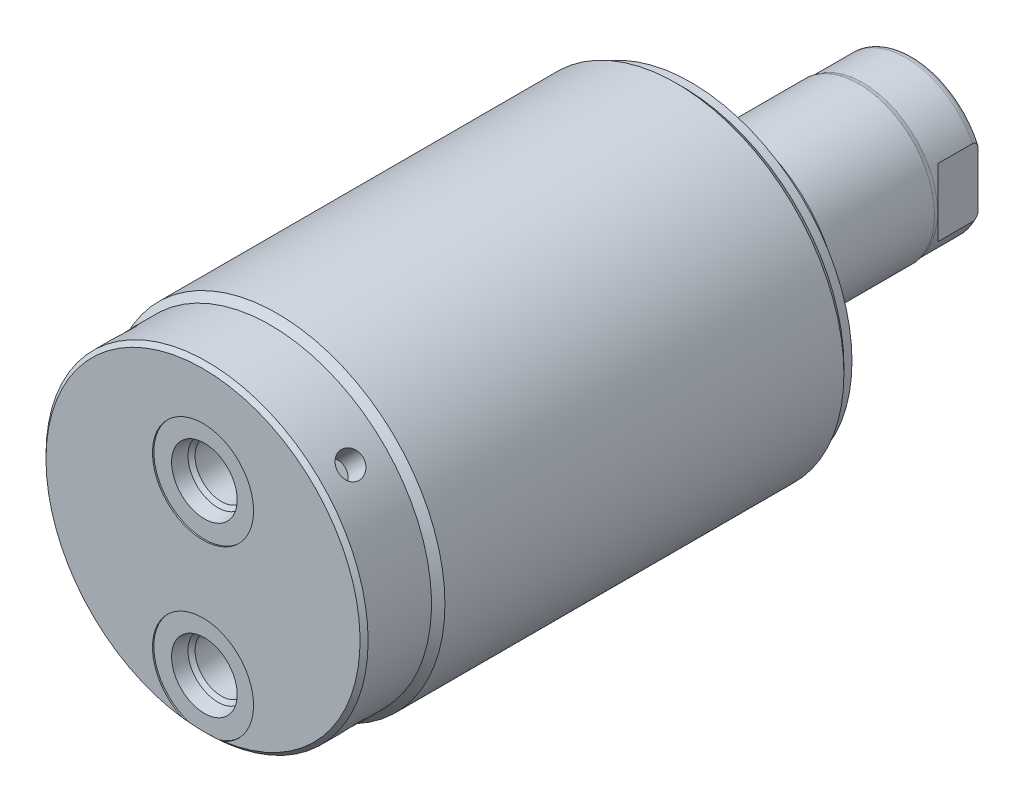
from build123d import *

# Parameters (mm, degrees)
SKETCH1_R          = 31.623
EXTRUDE1_DEPTH     = 91.948
CHAMFER1_SIZE      = 0.762
SKETCH6_R          = 22.225
EXTRUDE2_DEPTH     = 5.969
SKETCH7_W          = 35.56
SKETCH7_H          = 14.2875
CUT_EXTRUDE4_DEPTH = 19.84248
HOLE1_D            = 4.7498
HOLE1_DEPTH        = 4.7498
CIRPATTERN1_COUNT  = 4
LPATTERN2_COUNT    = 2
LPATTERN2_PITCH    = 31.75


with BuildPart() as part:
    # Sketch1 → Extrude1 (new body)
    with BuildSketch(Plane.XY):
        Circle(SKETCH1_R)
    extrude(amount=EXTRUDE1_DEPTH)

    # Sketch2 → Cut-Revolve1 (revolve, cut)
    with BuildSketch(Plane(origin=(0, 0, 0), x_dir=(1, 0, 0), z_dir=(0, 1, 0)), mode=Mode.PRIVATE) as cut_revolve1_sk:
        Polygon((31.623, -91.948), (31.623, -77.978), (30.353, -79.248), (30.353, -91.948), align=None)
    revolve(cut_revolve1_sk.sketch.rotate(Axis((0, 0, 0), (0, 0, 1)), 180), axis=Axis((0, 0, 0), (0, 0, 1)), mode=Mode.SUBTRACT)  # turned: the seam where the file's is

    # Sketch3 → Cut-Revolve2 (revolve, cut)
    with BuildSketch(Plane(origin=(0, 0, 0), x_dir=(1, 0, 0), z_dir=(0, 1, 0)), mode=Mode.PRIVATE) as cut_revolve2_sk:
        Polygon((30.353, 0), (30.353, -1.524), (31.623, -2.794), (31.623, 0), align=None)
    revolve(cut_revolve2_sk.sketch.rotate(Axis((0, 0, 0), (0, 0, -1)), 180), axis=Axis((0, 0, 0), (0, 0, -1)), mode=Mode.SUBTRACT)  # turned: the seam where the file's is

    # S2D0002 → Cut-Revolve3 (revolve, cut)
    with BuildSketch(Plane(origin=(0, 0, 0), x_dir=(0, -1, 0), z_dir=(1, 0, 0)), mode=Mode.PRIVATE) as cut_revolve3_sk:
        Polygon((-4.9403, -91.694), (-1.6002, -91.694), (-1.6002, -91.948), (-11.1252, -91.948), (-11.1252, -77.724), (-6.1468, -77.724), (-6.1468, -88.477393135), (-5.482893135, -89.1413), align=None)
    cut_revolve3 = revolve(cut_revolve3_sk.sketch.rotate(Axis((0, 11.1252, 14.6685), (0, 0, -1)), 270), axis=Axis((0, 11.1252, 14.6685), (0, 0, -1)), mode=Mode.SUBTRACT)  # turned: the seam where the file's is

    # Chamfer1
    chamfer1_edges = [part.edges().sort_by_distance(p)[0] for p in [
        (30.353, 0, 91.948),
    ]]
    chamfer(chamfer1_edges, length=CHAMFER1_SIZE)

    # Sketch6 → Extrude2 (add)
    with BuildSketch(Plane(origin=(0, 0, 0), x_dir=(-1, 0, 0), z_dir=(0, 0, -1))):
        with Locations(Location((0, 0, 0), (0, 0, 180))):  # turned: the seam where the file's is
            Circle(SKETCH6_R)
    extrude(amount=EXTRUDE2_DEPTH)

    # Sketch7 → Revolve1 (revolve)
    with BuildSketch(Plane(origin=(0, 0, 0), x_dir=(0, 0, -1), z_dir=(1, 0, 0)), mode=Mode.PRIVATE) as revolve1_sk:
        with Locations((23.749, -7.14375)):
            Rectangle(SKETCH7_W, SKETCH7_H)
    revolve(revolve1_sk.sketch.rotate(Axis((0, 0, 0), (0, 0, -1)), 270), axis=Axis((0, 0, 0), (0, 0, -1)))  # turned: the seam where the file's is

    # S2D0001 → Cut-Revolve5 (revolve, cut)
    with BuildSketch(Plane(origin=(0, 0, 0), x_dir=(1, 0, 0), z_dir=(0, 1, 0))):
        Polygon((5.5499, 39.461277746), (5.5499, 25.146), (0, 25.146), (0, 41.529), (6.7437, 41.529), align=None)
    revolve(axis=Axis((0, 0, 31.308359971), (0, 0, -1)), mode=Mode.SUBTRACT)

    # Sketch9 → Cut-Revolve6 (revolve, cut)
    with BuildSketch(Plane(origin=(0, 0, 0), x_dir=(0, -1, 0), z_dir=(1, 0, 0)), mode=Mode.PRIVATE) as cut_revolve6_sk:
        with BuildLine():
            Line((-14.2875, 31.623), (-14.097, 32.385))
            Line((-14.097, 32.385), (-14.097, 40.513))
            ThreePointArc((-14.097, 40.513), (-13.996678675, 41.056796865), (-13.708922533, 41.529))
            Line((-13.708922533, 41.529), (-14.2875, 41.529))
            Line((-14.2875, 41.529), (-14.2875, 31.623))
        make_face()
    revolve(cut_revolve6_sk.sketch.rotate(Axis((0, 0, -12.65936), (0, 0, -1)), 90), axis=Axis((0, 0, -12.65936), (0, 0, -1)), mode=Mode.SUBTRACT)  # turned: the seam where the file's is

    # Sketch13 → Cut-Extrude4 (cut, symmetric)
    with BuildSketch(Plane(origin=(0, 0, 0), x_dir=(1, 0, 0), z_dir=(0, 1, 0))):
        Polygon((12.573, 41.529), (12.573, 33.9598), (14.2875, 32.2453), (14.2875, 41.529), align=None)
        Polygon((-12.573, 41.529), (-12.573, 33.9598), (-14.2875, 32.2453), (-14.2875, 41.529), align=None)
    extrude(amount=CUT_EXTRUDE4_DEPTH, both=True, mode=Mode.SUBTRACT)

    # Hole1
    with Locations(Plane(origin=(-21.462812129, 21.462812129, 85.598), x_dir=(0.707106781, 0.707106781, 0), z_dir=(-0.707106781, 0.707106781, 0))):
        with Locations((0, 0)):
            hole1 = Hole(HOLE1_D / 2, depth=HOLE1_DEPTH)

    # CirPattern1: Hole1 ×4 about axis
    cirpattern1_axis = Axis((0, 0, 0), (0, 0, 1))
    for i in range(1, CIRPATTERN1_COUNT):
        add(hole1.rotate(cirpattern1_axis, i * 360 / CIRPATTERN1_COUNT), mode=Mode.SUBTRACT)

    # LPattern2: Cut-Revolve3 ×2
    with Locations(*[(0, -i * LPATTERN2_PITCH, 0) for i in range(1, LPATTERN2_COUNT)]):
        add(cut_revolve3, mode=Mode.SUBTRACT)


solid = part.part
